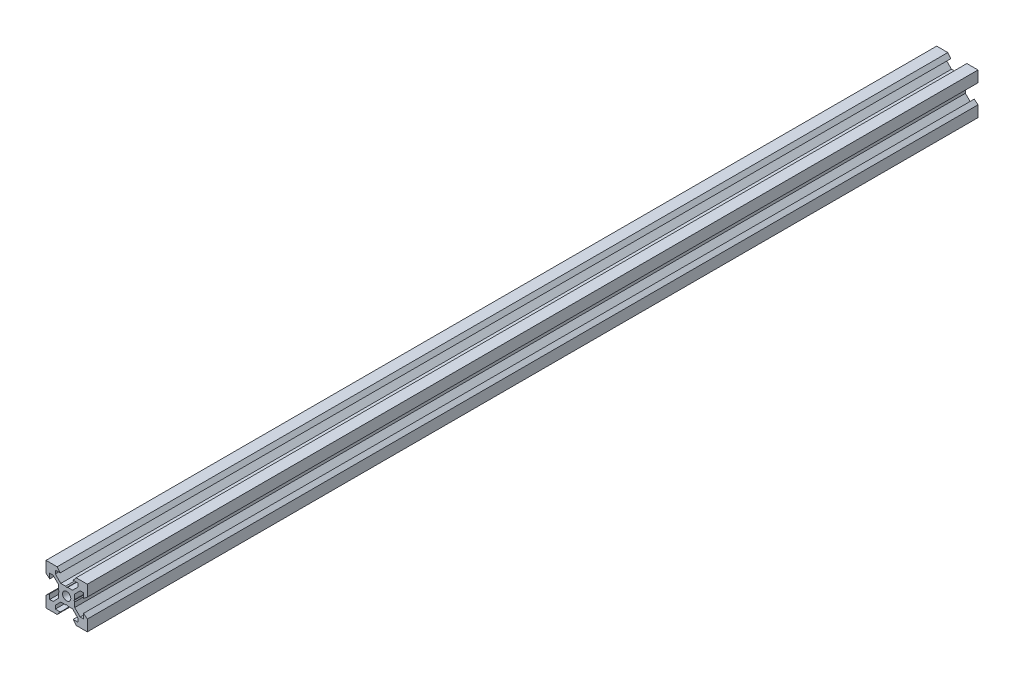
from build123d import *

# Parameters (mm, degrees)
SKETCH1_R           = 2
BOSS_EXTRUDE1_DEPTH = 215.6


with BuildPart() as part:
    # Sketch1 → Boss-Extrude1 (new body, symmetric)
    with BuildSketch(Plane.XY):
        Polygon((10, 10), (10, 4.610379336), (8.2, 3.1), (8.2, 5.5), (6.560660172, 5.5), (3.9, 2.839339828), (3.9, 0.519615242), (3.6, 0), (3.9, -0.519615242), (3.9, -2.839339828), (6.560660172, -5.5), (8.2, -5.5), (8.2, -3.1), (10, -4.610379336), (10, -10), (4.610379336, -10), (3.1, -8.2), (5.5, -8.2), (5.5, -6.560660172), (2.839339828, -3.9), (0.519615242, -3.9), (0, -3.6), (-0.519615242, -3.9), (-2.839339828, -3.9), (-5.5, -6.560660172), (-5.5, -8.2), (-3.1, -8.2), (-4.610379336, -10), (-10, -10), (-10, -4.610379336), (-8.2, -3.1), (-8.2, -5.5), (-6.560660172, -5.5), (-3.9, -2.839339828), (-3.9, -0.519615242), (-3.6, 0), (-3.9, 0.519615242), (-3.9, 2.839339828), (-6.560660172, 5.5), (-8.2, 5.5), (-8.2, 3.1), (-10, 4.610379336), (-10, 10), (-4.610379336, 10), (-3.1, 8.2), (-5.5, 8.2), (-5.5, 6.560660172), (-2.839339828, 3.9), (-0.519615242, 3.9), (0, 3.6), (0.519615242, 3.9), (2.839339828, 3.9), (5.5, 6.560660172), (5.5, 8.2), (3.1, 8.2), (4.610379336, 10), align=None)
        Circle(SKETCH1_R, mode=Mode.SUBTRACT)
    extrude(amount=BOSS_EXTRUDE1_DEPTH, both=True)


solid = part.part
